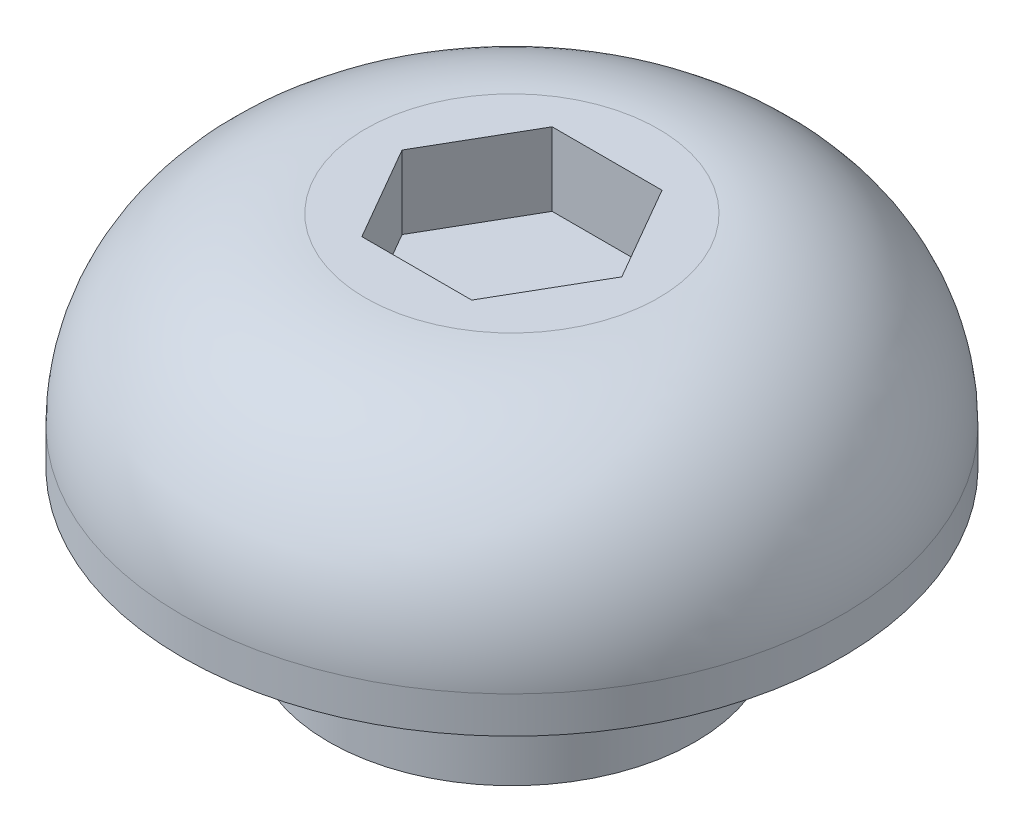
from build123d import *

# Parameters (mm, degrees)
SKETCH1_R           = 4.5
BOSS_EXTRUDE1_DEPTH = 3
FILLET1_R           = 2.5
CUT_EXTRUDE1_DEPTH  = 1
SKETCH3_R           = 2.5
BOSS_EXTRUDE2_DEPTH = 2


with BuildPart() as part:
    # Sketch1 → Boss-Extrude1 (new body)
    with BuildSketch(Plane(origin=(0, 0, 0), x_dir=(1, 0, 0), z_dir=(0, 1, 0))):
        Circle(SKETCH1_R)
    extrude(amount=BOSS_EXTRUDE1_DEPTH)

    # Fillet1
    fillet1_edges = [part.edges().sort_by_distance(p)[0] for p in [
        (-4.5, 3, 0),
    ]]
    fillet(fillet1_edges, radius=FILLET1_R)

    # Sketch2 → Cut-Extrude1 (cut)
    with BuildSketch(Plane(origin=(0, 3, 0), x_dir=(1, 0, 0), z_dir=(0, 1, 0))):
        Polygon((1.5, 0), (0.75, 1.299038106), (-0.75, 1.299038106), (-1.5, 0), (-0.75, -1.299038106), (0.75, -1.299038106), align=None)
    extrude(amount=-CUT_EXTRUDE1_DEPTH, mode=Mode.SUBTRACT)

    # Sketch3 → Boss-Extrude2 (add)
    with BuildSketch(Plane(origin=(0, 0, 0), x_dir=(-1, 0, 0), z_dir=(0, -1, 0))):
        Circle(SKETCH3_R)
    extrude(amount=BOSS_EXTRUDE2_DEPTH)


solid = part.part
